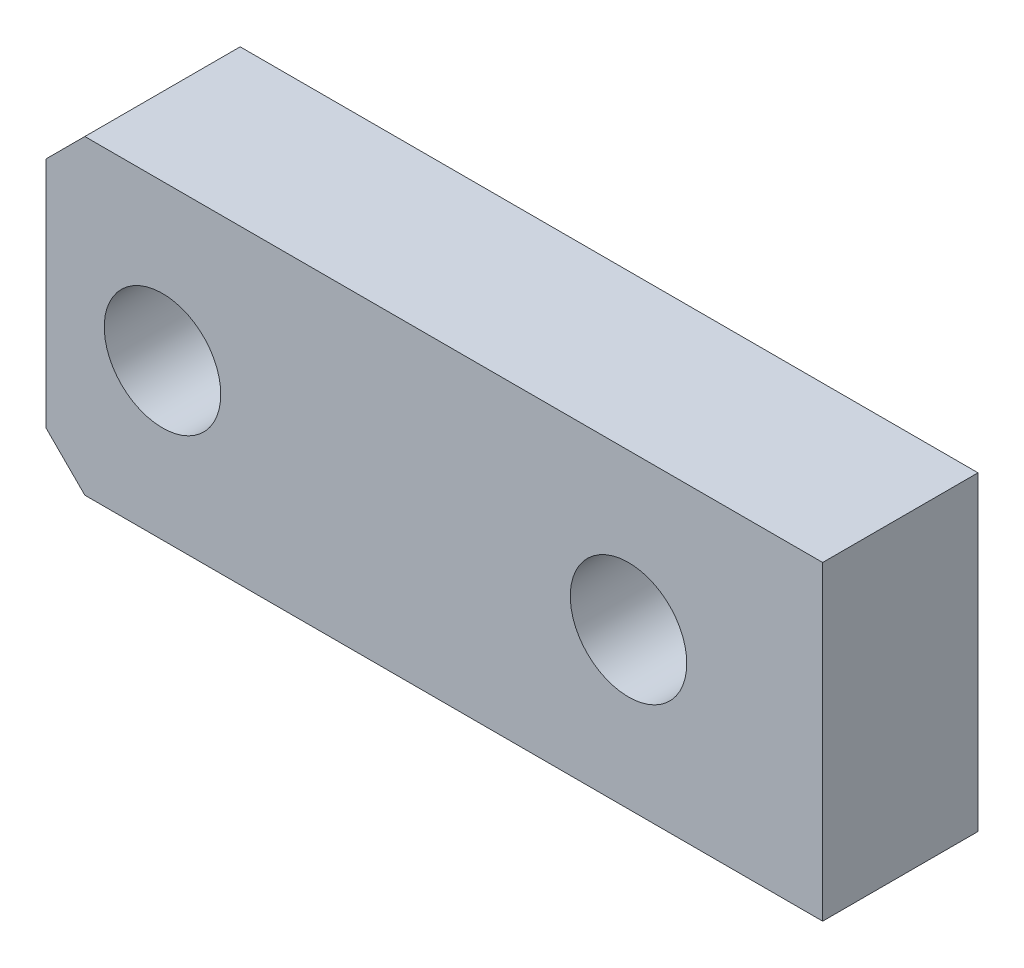
from build123d import *

# Parameters (mm, degrees)
SKETCH1_W      = 20
SKETCH1_H      = 8
EXTRUDE1_DEPTH = 4
CHAMFER1_SIZE  = 1
SKETCH2_R      = 1.5
EXTRUDE2_DEPTH = 4


with BuildPart() as part:
    # Sketch1 → Extrude1 (new body)
    with BuildSketch(Plane.XY):
        Rectangle(SKETCH1_W, SKETCH1_H)
    extrude(amount=EXTRUDE1_DEPTH)

    # Chamfer1
    chamfer1_edges = [part.edges().sort_by_distance(p)[0] for p in [
        (-10, -4, 2),
        (-10, 4, 2),
    ]]
    chamfer(chamfer1_edges, length=CHAMFER1_SIZE)

    # Sketch2 → Extrude2 (cut)
    with BuildSketch(Plane.XY.offset(4)):
        with Locations((-7, 0)):
            Circle(SKETCH2_R)
        with Locations((5, 0)):
            Circle(SKETCH2_R)
    extrude(amount=-EXTRUDE2_DEPTH, mode=Mode.SUBTRACT)


solid = part.part
